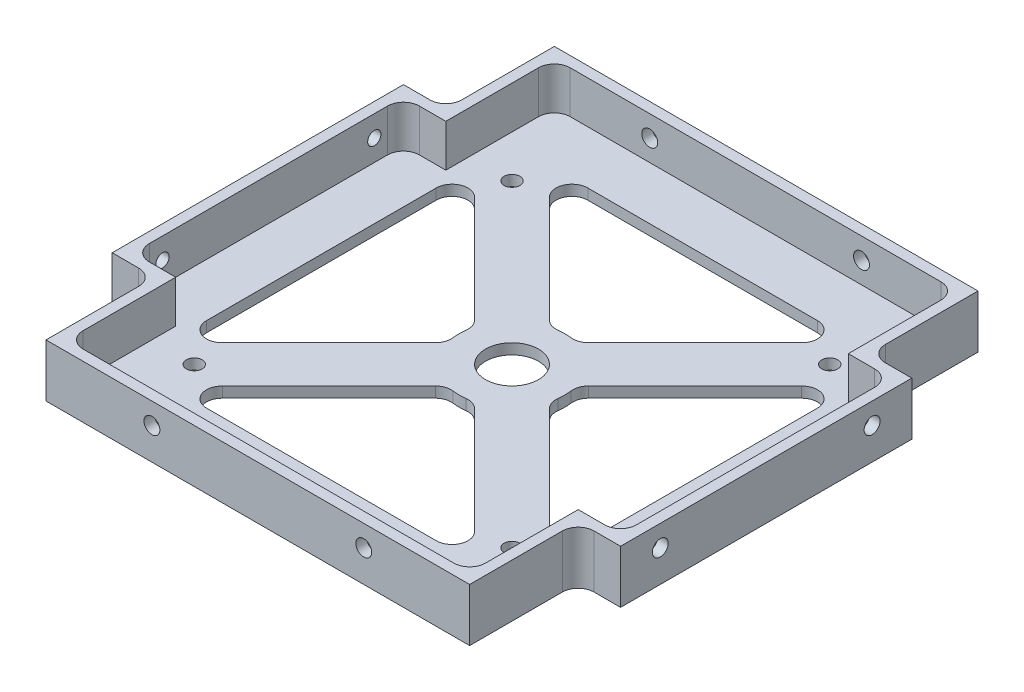
from build123d import *

# Parameters (mm, degrees)
BOSS_EXTRUDE1_DEPTH             = 10
SKETCH2_R                       = 5
CUT_EXTRUDE1_DEPTH              = 11
FILLET1_R                       = 3
CUT_EXTRUDE4_DEPTH              = 11
CUT_EXTRUDE5_DEPTH              = 8
FILLET2_R                       = 3
F_3_0MM_DOWEL_HOLE1_AT_2_COUNT  = 2
F_3_0MM_DOWEL_HOLE1_AT_2_PITCH  = 40
TAP_DRILL_FOR_M3X0_5_TAP1_D     = 2.5
TAP_DRILL_FOR_M3X0_5_TAP1_DEPTH = 2
F_3_0MM_DOWEL_HOLE3_D           = 3
F_3_0MM_DOWEL_HOLE4_D           = 3
F_3_0MM_DOWEL_HOLE4_DEPTH       = 2


with BuildPart() as part:
    # Sketch1 → Boss-Extrude1 (new body)
    with BuildSketch(Plane(origin=(0, 0, 0), x_dir=(1, 0, 0), z_dir=(0, 1, 0))):
        Polygon((0, 88), (0, 8), (8, 0), (88, 0), (96, 8), (96, 88), (88, 96), (8, 96), align=None)
    extrude(amount=BOSS_EXTRUDE1_DEPTH)

    # Sketch2 → Cut-Extrude1 (cut, through all)
    with BuildSketch(Plane(origin=(0, 0, 0), x_dir=(-1, 0, 0), z_dir=(0, -1, 0))):
        with BuildLine():
            Line((-45.411809549, 57.659258263), (-19.071067812, 84))
            Line((-19.071067812, 84), (-76.928932188, 84))
            Line((-76.928932188, 84), (-50.588190451, 57.659258263))
            ThreePointArc((-50.588190451, 57.659258263), (-48, 58), (-45.411809549, 57.659258263))
        make_face()
        with BuildLine():
            Line((-12, 76.928932188), (-38.340741737, 50.588190451))
            ThreePointArc((-38.340741737, 50.588190451), (-38.085551386, 49.305261922), (-38, 48))
            ThreePointArc((-38, 48), (-38.085551386, 46.694738078), (-38.340741737, 45.411809549))
            Line((-38.340741737, 45.411809549), (-12, 19.071067812))
            Line((-12, 19.071067812), (-12, 76.928932188))
        make_face()
        with BuildLine():
            Line((-19.071067812, 12), (-45.411809549, 38.340741737))
            ThreePointArc((-45.411809549, 38.340741737), (-48, 38), (-50.588190451, 38.340741737))
            Line((-50.588190451, 38.340741737), (-76.928932188, 12))
            Line((-76.928932188, 12), (-19.071067812, 12))
        make_face()
        with BuildLine():
            ThreePointArc((-57.659258263, 45.411809549), (-58, 48), (-57.659258263, 50.588190451))
            Line((-57.659258263, 50.588190451), (-84, 76.928932188))
            Line((-84, 76.928932188), (-84, 19.071067812))
            Line((-84, 19.071067812), (-57.659258263, 45.411809549))
        make_face()
        with Locations((-48, 48)):
            Circle(SKETCH2_R)
    extrude(amount=-CUT_EXTRUDE1_DEPTH, mode=Mode.SUBTRACT)

    # Fillet1
    fillet1_edges = [part.edges().sort_by_distance(p)[0] for p in [
        (50.588190451, 5, -38.340741737),
        (45.411809549, 5, -38.340741737),
        (19.071067812, 5, -12),
        (76.928932188, 5, -12),
        (38.340741737, 5, -45.411809549),
        (38.340741737, 5, -50.588190451),
        (12, 5, -76.928932188),
        (12, 5, -19.071067812),
        (57.659258263, 5, -50.588190451),
        (57.659258263, 5, -45.411809549),
        (84, 5, -19.071067812),
        (84, 5, -76.928932188),
        (45.411809549, 5, -57.659258263),
        (50.588190451, 5, -57.659258263),
        (76.928932188, 5, -84),
        (19.071067812, 5, -84),
    ]]
    fillet(fillet1_edges, radius=FILLET1_R)

    # Sketch5 → Cut-Extrude4 (cut, through all)
    with BuildSketch(Plane(origin=(0, 10, 0), x_dir=(1, 0, 0), z_dir=(0, 1, 0))):
        Polygon((8, 0), (8, 20.5), (0, 20.5), (0, 8), align=None)
        Polygon((96, 8), (88, 0), (88, 20.5), (96, 20.5), align=None)
        Polygon((96, 75.5), (88, 75.5), (88, 96), (96, 88), align=None)
        Polygon((8, 96), (8, 75.5), (0, 75.5), (0, 88), align=None)
    extrude(amount=-CUT_EXTRUDE4_DEPTH, mode=Mode.SUBTRACT)

    # Sketch6 → Cut-Extrude5 (cut)
    with BuildSketch(Plane(origin=(0, 10, 0), x_dir=(1, 0, 0), z_dir=(0, 1, 0))):
        Polygon((86, 73.5), (86, 94), (10, 94), (10, 73.5), (2, 73.5), (2, 22.5), (10, 22.5), (10, 2), (86, 2), (86, 22.5), (94, 22.5), (94, 73.5), align=None)
    extrude(amount=-CUT_EXTRUDE5_DEPTH, mode=Mode.SUBTRACT)

    # Fillet2
    fillet2_edges = [part.edges().sort_by_distance(p)[0] for p in [
        (8, 5, -75.5),
        (88, 5, -75.5),
        (88, 5, -20.5),
        (8, 5, -20.5),
        (94, 6, -73.5),
        (94, 6, -22.5),
        (86, 6, -2),
        (10, 6, -2),
        (2, 6, -22.5),
        (2, 6, -73.5),
        (10, 6, -94),
        (86, 6, -94),
    ]]
    fillet(fillet2_edges, radius=FILLET2_R)

    # Sketch13 → Ø3.0mm Dowel Hole1 (revolve, cut)
    with BuildSketch(Plane(origin=(28, 6, 0), x_dir=(0, -1, 0), z_dir=(1, 0, 0))):
        Polygon((0, 0), (0, 8.401290929), (1.5, 7.5), (1.5, 0), align=None)
    f_3_0mm_dowel_hole1 = revolve(axis=Axis((28, 6, 6.35), (0, 0, -1)), mode=Mode.SUBTRACT)

    # Ø3.0mm Dowel Hole1 at 2: Ø3.0mm Dowel Hole1 ×2
    with Locations(*[(i * F_3_0MM_DOWEL_HOLE1_AT_2_PITCH, 0, 0) for i in range(1, F_3_0MM_DOWEL_HOLE1_AT_2_COUNT)]):
        add(f_3_0mm_dowel_hole1, mode=Mode.SUBTRACT)

    # Tap Drill for M3x0.5 Tap1
    with Locations(Plane.ZY):
        with Locations((-68, 6), (-28, 6)):
            Hole(TAP_DRILL_FOR_M3X0_5_TAP1_D / 2, depth=TAP_DRILL_FOR_M3X0_5_TAP1_DEPTH)

    # Mirror1: Ø3.0mm Dowel Hole1 across plane
    add(f_3_0mm_dowel_hole1.mirror(Plane.XY.offset(-48)), mode=Mode.SUBTRACT)

    # Mirror1 copy 1 sketch → Mirror1 copy 1 (revolve, cut)
    with BuildSketch(Plane(origin=(68, 6, -96), x_dir=(0, -1, 0), z_dir=(1, 0, 0))):
        Polygon((0, 0), (0, -8.401290929), (1.5, -7.5), (1.5, 0), align=None)
    revolve(axis=Axis((68, 6, -102.35), (0, 0, -1)), mode=Mode.SUBTRACT)

    # Ø3.0mm Dowel Hole3 (through all)
    with Locations(Plane(origin=(78, 0, -18), x_dir=(0, 0, -1), z_dir=(0, -1, 0))):
        with Locations((0, 0), (60, 0), (60, -60), (0, -60)):
            Hole(F_3_0MM_DOWEL_HOLE3_D / 2)

    # Ø3.0mm Dowel Hole4
    with Locations(Plane(origin=(96, 6, -68), x_dir=(0, 0, 1), z_dir=(1, 0, 0))):
        with Locations((0, 0), (40, 0)):
            Hole(F_3_0MM_DOWEL_HOLE4_D / 2, depth=F_3_0MM_DOWEL_HOLE4_DEPTH)


solid = part.part
